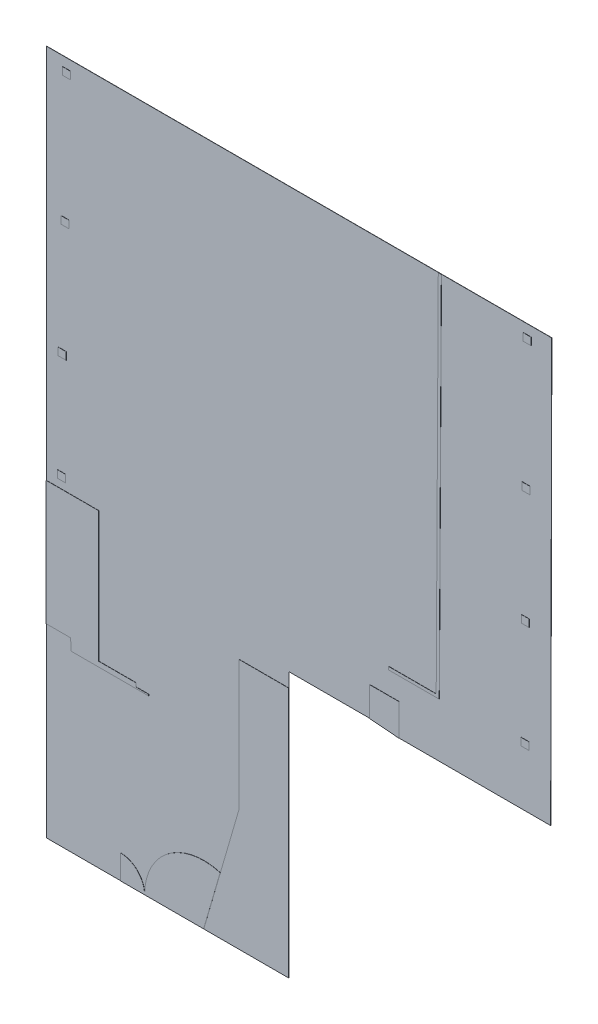
from build123d import *

# Parameters (mm, degrees)
SALIENTE_EXTRUIR1_DEPTH = 10
CROQUIS2_W              = 393.7
CROQUIS2_H              = 368.3
SALIENTE_EXTRUIR2_DEPTH = 10
SALIENTE_EXTRUIR7_DEPTH = 10
EXTRUIR_L_MINA5_DEPTH   = 1


with BuildPart() as part:
    # Croquis1 → Saliente-Extruir1 (new body)
    with BuildSketch(Plane.XY):
        Polygon((0, 0), (25000, 0), (24950, -20920.804148799), (17450, -20920.804148799), (17450, -19350.804148799), (16000, -19350.804148799), (16000, -20800.804148799), (12000, -20800.804148799), (12000, -33920.804148799), (0, -33920.804148799), (0, -24740.804148799), (1210, -24740.804148799), (1240, -25300), (5070, -25300), (5070, -25230), (4440, -25230), (4440, -25050), (2600, -25050), (2600, -18600), (0, -18600), align=None)
    extrude(amount=SALIENTE_EXTRUIR1_DEPTH)

    # Croquis2 → Saliente-Extruir2 (add)
    with BuildSketch(Plane.XY.offset(10)):
        with Locations((996.85, -654.15)):
            Rectangle(CROQUIS2_W, CROQUIS2_H)
        with Locations((926.85, -7072.45)):
            Rectangle(CROQUIS2_W, CROQUIS2_H)
        with Locations((755.65, -18045.85)):
            Rectangle(CROQUIS2_W, CROQUIS2_H)
        with Locations((793.75, -12777.55)):
            Rectangle(CROQUIS2_W, CROQUIS2_H)
        Polygon((19446.365471508, -18250.804148799), (16946.365471508, -18250.804148799), (16946.365471508, -18100.804148799), (19297.214806363, -18100.804148799), (19399.997581742, 0), (19550, 0), align=None)
        Polygon((16000, -20800.804148799), (17450, -20920.804148799), (17450, -19350.804148799), (16000, -19350.804148799), align=None)
        Polygon((12000, -21500.804148799), (9550, -21500.804148799), (9550, -27900.804148799), (7800, -33920.804148799), (12000, -33920.804148799), (12000, -27900.804148799), align=None)
        with BuildLine():
            Line((3670, -33920.804148799), (3670, -32720.804148799))
            ThreePointArc((3670, -32720.804148799), (4518.528137424, -33072.276011376), (4870, -33920.804148799))
            Line((4870, -33920.804148799), (3670, -33920.804148799))
        make_face()
        Polygon((0, -18600), (0, -24740.804148799), (1210, -24740.804148799), (1240, -25300), (5070, -25300), (5070, -25230), (4440, -25230), (4440, -25050), (2600, -25050), (2600, -18600), align=None)
        with Locations((23793.15, -654.15)):
            Rectangle(CROQUIS2_W, CROQUIS2_H)
        with Locations((23735.803977642, -7072.45)):
            Rectangle(CROQUIS2_W, CROQUIS2_H)
        with Locations((23702.168928389, -12777.55)):
            Rectangle(CROQUIS2_W, CROQUIS2_H)
        with Locations((23689.577873183, -18045.85)):
            Rectangle(CROQUIS2_W, CROQUIS2_H)
    extrude(amount=SALIENTE_EXTRUIR2_DEPTH)

    # Croquis3 → Saliente-Extruir7 (add)
    with BuildSketch(Plane.XY.offset(10)):
        with BuildLine():
            Line((7800, -33920.804148799), (4869.875696963, -33920.804148799))
            ThreePointArc((4869.875696963, -33920.804148799), (6040.878653489, -31577.490145193), (8617.921821699, -31107.153082154))
            Line((8617.921821699, -31107.153082154), (7800, -33920.804148799))
        make_face()
    extrude(amount=SALIENTE_EXTRUIR7_DEPTH)

    # Croquis4 → Extruir-Lámina5 (add)
    with BuildSketch(Plane.XY.offset(20)):
        Polygon((8617.921821699, -31107.153082154), (7799.43148405, -33922.759843667), (7789.828986765, -33919.968420037), (8608.319324414, -31104.361658524), align=None)
    extrude(amount=EXTRUIR_L_MINA5_DEPTH)


solid = part.part
